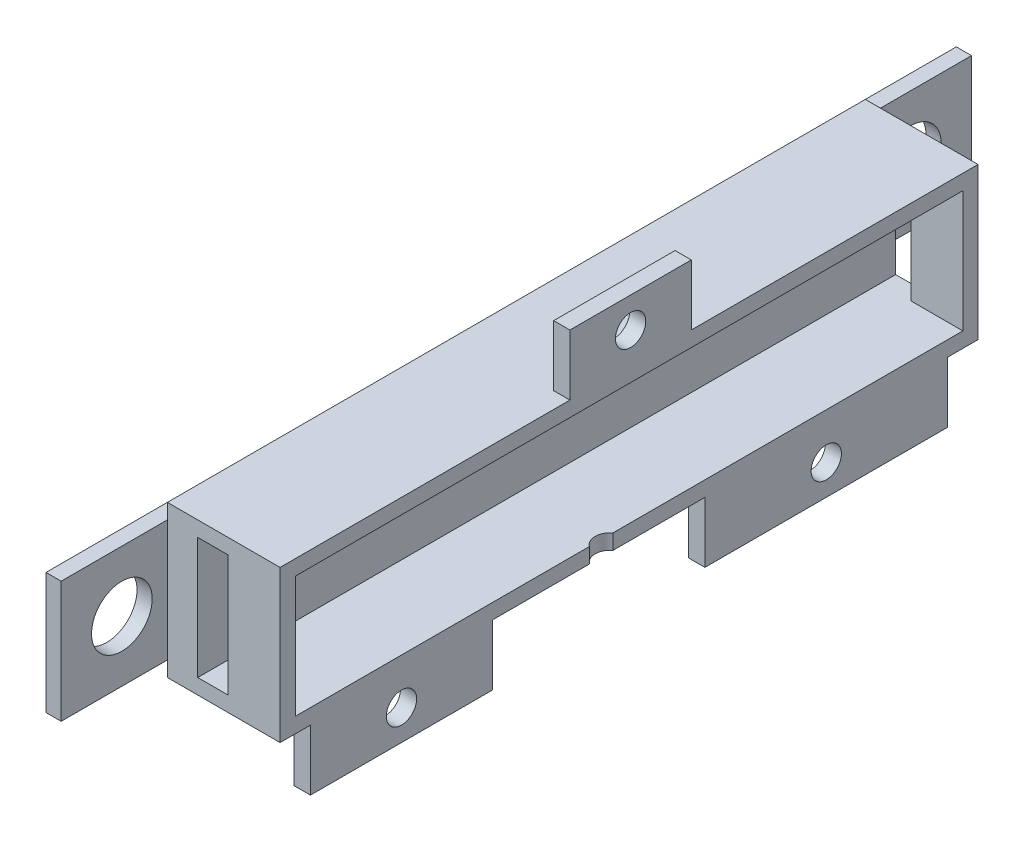
from build123d import *

# Parameters (mm, degrees)
SKETCH1_W               = 190.5
SKETCH1_H               = 25.4
SKETCH1_R               = 6.35
BOSS_EXTRUDE1_DEPTH     = 3.175
SKETCH2_W               = 146.05
SKETCH2_H               = 3.175
BOSS_EXTRUDE2_DEPTH     = 47.625
BOSS_EXTRUDE2_2_DEPTH   = 47.625
SKETCH3_W               = 146.05
SKETCH3_H               = 25.4
BOSS_EXTRUDE4_DEPTH     = 6.35
SKETCH4_W               = 3.175
SKETCH4_H               = 25.4
BOSS_EXTRUDE5_DEPTH     = 41.275
SKETCH5_W               = 6.35
SKETCH5_H               = 25.4
CUT_EXTRUDE1_DEPTH      = 165.45
SKETCH7_W               = 146.05
SKETCH7_H               = 31.75
BOSS_EXTRUDE7_DEPTH     = 3.175
FILLET1_R               = 10
SKETCH8_R               = 3.05
CUT_EXTRUDE2_DEPTH      = 3.175
SKETCH9_W               = 6.35
SKETCH9_H               = 38.1
SKETCH9_H_2             = 50.8
BOSS_EXTRUDE8_DEPTH     = 12.7
SKETCH10_R              = 3.175
CUT_EXTRUDE3_DEPTH      = 12.7
SKETCH11_W              = 6.35
SKETCH11_H              = 25.4
BOSS_EXTRUDE9_DEPTH     = 12.7
SKETCH12_R              = 3.175
CUT_EXTRUDE4_DEPTH      = 12.7
SKETCH13_W              = 28.740264125
SKETCH13_H              = 146.120317421
CUT_EXTRUDE5_DEPTH      = 50.8
CUT_EXTRUDE5_DEPTH_BACK = 50.8


with BuildPart() as part:
    # Sketch1 → Boss-Extrude1 (new body)
    with BuildSketch(Plane(origin=(0, 0, 0), x_dir=(0, 0, -1), z_dir=(1, 0, 0))):
        with Locations((-50.270833333, 2.116666667)):
            Rectangle(SKETCH1_W, SKETCH1_H)
        with Locations((32.279166667, 2.116666667)):
            Circle(SKETCH1_R, mode=Mode.SUBTRACT)
        with Locations((-132.820833333, 2.116666667)):
            Circle(SKETCH1_R, mode=Mode.SUBTRACT)
    extrude(amount=BOSS_EXTRUDE1_DEPTH)



with BuildPart() as body_2:
    # Sketch2 → Boss-Extrude2 (new body)
    with BuildSketch(Plane(origin=(3.175, 0, 0), x_dir=(0, 0, -1), z_dir=(1, 0, 0))):
        with Locations((-50.270833333, 16.404166667)):
            Rectangle(SKETCH2_W, SKETCH2_H)
    extrude(amount=BOSS_EXTRUDE2_DEPTH)


with BuildPart() as body_3:
    # Sketch2 → Boss-Extrude2 2 (new body)
    with BuildSketch(Plane(origin=(3.175, 0, 0), x_dir=(0, 0, -1), z_dir=(1, 0, 0))):
        with Locations((-50.270833333, -12.170833333)):
            Rectangle(SKETCH2_W, SKETCH2_H)
    extrude(amount=BOSS_EXTRUDE2_2_DEPTH)


with BuildPart() as part_1:
    add(part.part)

    add(body_2.part)  # Boss-Extrude4 merges body 2

    add(body_3.part)  # Boss-Extrude4 merges body 3
    # Sketch3 → Boss-Extrude4 (add)
    with BuildSketch(Plane(origin=(3.175, 0, 0), x_dir=(0, 0, -1), z_dir=(1, 0, 0))):
        with Locations((-50.270833333, 2.116666667)):
            Rectangle(SKETCH3_W, SKETCH3_H)
    extrude(amount=BOSS_EXTRUDE4_DEPTH)

    # Sketch4 → Boss-Extrude5 (add)
    with BuildSketch(Plane(origin=(9.525, 0, 0), x_dir=(0, 0, -1), z_dir=(1, 0, 0))):
        with Locations((-121.708333333, 2.116666667)):
            Rectangle(SKETCH4_W, SKETCH4_H)
        with Locations((21.166666667, 2.116666667)):
            Rectangle(SKETCH4_W, SKETCH4_H)
    extrude(amount=BOSS_EXTRUDE5_DEPTH)

    # Sketch5 → Cut-Extrude1 (cut)
    with BuildSketch(Plane.XY.offset(123.295833333)):
        with Locations((12.7, 2.116666667)):
            Rectangle(SKETCH5_W, SKETCH5_H)
    extrude(amount=-CUT_EXTRUDE1_DEPTH, mode=Mode.SUBTRACT)

    # Sketch7 → Boss-Extrude7 (add)
    with BuildSketch(Plane(origin=(50.8, 0, 0), x_dir=(0, 0, -1), z_dir=(1, 0, 0))):
        with Locations((-50.270833333, 2.116666667)):
            Rectangle(SKETCH7_W, SKETCH7_H)
    extrude(amount=BOSS_EXTRUDE7_DEPTH)

    # Fillet1
    fillet1_edges = [part_1.edges().sort_by_distance(p)[0] for p in [
        (53.975, 2.116666667, 123.295833333),
        (53.975, -13.758333333, 50.270833333),
        (53.975, 2.116666667, -22.754166667),
        (53.975, 17.991666667, 50.270833333),
    ]]
    fillet(fillet1_edges, radius=FILLET1_R)

    # Sketch8 → Cut-Extrude2 (cut)
    with BuildSketch(Plane.XZ.offset(13.758333333)):
        with Locations((28.575, 56.120833333)):
            Circle(SKETCH8_R)
    extrude(amount=-CUT_EXTRUDE2_DEPTH, mode=Mode.SUBTRACT)

    # Sketch9 → Boss-Extrude8 (add)
    with BuildSketch(Plane.XZ.offset(13.758333333)):
        with Locations((26.541679323, 97.895833333)):
            Rectangle(SKETCH9_W, SKETCH9_H)
        with Locations((26.541679323, 8.995833333)):
            Rectangle(SKETCH9_W, SKETCH9_H_2)
    extrude(amount=BOSS_EXTRUDE8_DEPTH)

    # Sketch10 → Cut-Extrude3 (cut)
    with BuildSketch(Plane(origin=(29.716679323, 0, 0), x_dir=(0, 0, -1), z_dir=(1, 0, 0))):
        with Locations((-97.895833333, -20.108333333)):
            Circle(SKETCH10_R)
        with Locations((-8.995833333, -20.108333333)):
            Circle(SKETCH10_R)
    extrude(amount=-CUT_EXTRUDE3_DEPTH, mode=Mode.SUBTRACT)

    # Sketch11 → Boss-Extrude9 (add)
    with BuildSketch(Plane(origin=(0, 17.991666667, 0), x_dir=(1, 0, 0), z_dir=(0, 1, 0))):
        with Locations((26.54, -49.945833333)):
            Rectangle(SKETCH11_W, SKETCH11_H)
    extrude(amount=BOSS_EXTRUDE9_DEPTH)

    # Sketch12 → Cut-Extrude4 (cut)
    with BuildSketch(Plane(origin=(29.715, 0, 0), x_dir=(0, 0, -1), z_dir=(1, 0, 0))):
        with Locations((-49.945833333, 24.341666667)):
            Circle(SKETCH12_R)
    extrude(amount=-CUT_EXTRUDE4_DEPTH, mode=Mode.SUBTRACT)

    # Sketch13 → Cut-Extrude5 (cut, two sides)
    with BuildSketch(Plane.XZ.offset(13.758333333)) as cut_extrude5_sk:
        with Locations((41.13133077, 50.235674622)):
            Rectangle(SKETCH13_W, SKETCH13_H)
    extrude(amount=CUT_EXTRUDE5_DEPTH, mode=Mode.SUBTRACT)
    extrude(cut_extrude5_sk.sketch, amount=-CUT_EXTRUDE5_DEPTH_BACK, mode=Mode.SUBTRACT)


solid = part_1.part
